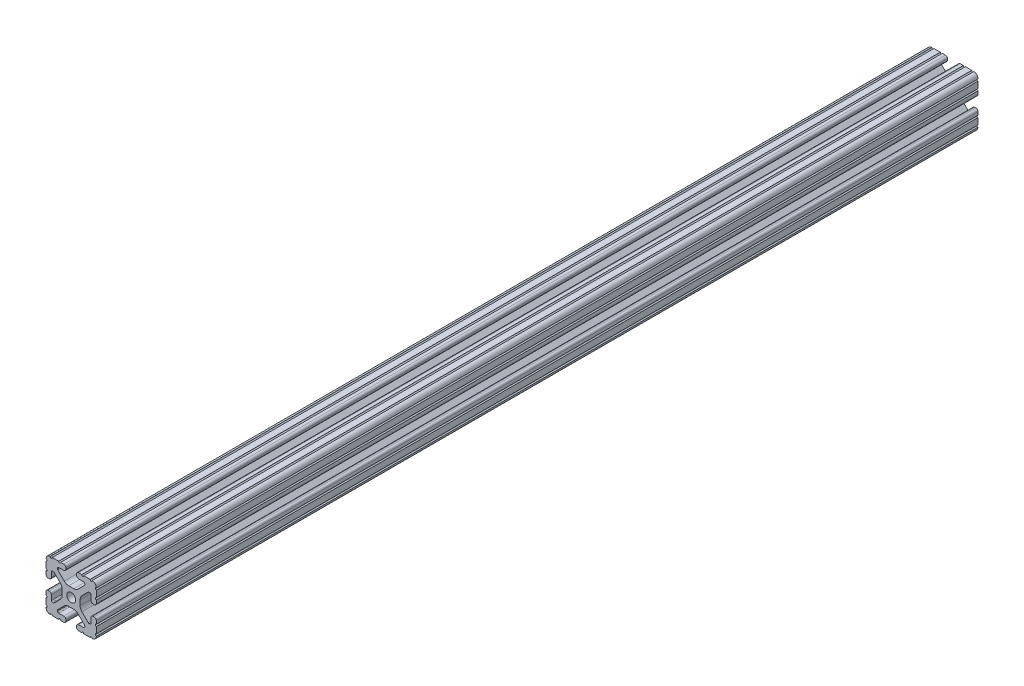
from build123d import *

# Parameters (mm, degrees)
SKETCH1_R               = 3.3274
BOSS_EXTRUDE1_DEPTH     = 609.6
SKETCH2_W               = 555.737416111
SKETCH2_H               = 51.354372661
CUT_EXTRUDE1_DEPTH      = 5.08
CUT_EXTRUDE1_DEPTH_BACK = 41.148


with BuildPart() as part:
    # Sketch1 → Boss-Extrude1 (new body, symmetric)
    with BuildSketch(Plane.XY):
        with BuildLine():
            Line((-10.287, 13.552357131), (-10.287, 14.0843))
            ThreePointArc((-10.287, 14.0843), (-10.022898185, 14.721898185), (-9.3853, 14.986))
            Line((-9.3853, 14.986), (-5.617617549, 14.986))
            ThreePointArc((-5.617617549, 14.986), (-4.519044045, 15.441044045), (-4.064, 16.539617549))
            Line((-4.064, 16.539617549), (-4.064, 17.496382451))
            ThreePointArc((-4.064, 17.496382451), (-4.519044045, 18.594955955), (-5.617617549, 19.05))
            Line((-5.617617549, 19.05), (-7.974178704, 19.05))
            ThreePointArc((-7.974178704, 19.05), (-8.736178704, 18.288), (-9.498178704, 19.05))
            Line((-9.498178704, 19.05), (-14.327719207, 19.05))
            ThreePointArc((-14.327719207, 19.05), (-15.087603123, 18.231251131), (-15.847487039, 19.05))
            ThreePointArc((-15.847487039, 19.05), (-18.120176289, 18.120192083), (-19.05, 15.847509295))
            ThreePointArc((-19.05, 15.847509295), (-18.231250992, 15.08762539), (-19.05, 14.327741484))
            Line((-19.05, 14.327741484), (-19.05, 9.496091471))
            ThreePointArc((-19.05, 9.496091471), (-18.231250992, 8.736207565), (-19.05, 7.97632366))
            Line((-19.05, 7.97632366), (-19.05, 5.617617549))
            ThreePointArc((-19.05, 5.617617549), (-18.594955955, 4.519044045), (-17.496382451, 4.064))
            Line((-17.496382451, 4.064), (-16.539617549, 4.064))
            ThreePointArc((-16.539617549, 4.064), (-15.441044045, 4.519044045), (-14.986, 5.617617549))
            Line((-14.986, 5.617617549), (-14.986, 9.385342516))
            ThreePointArc((-14.986, 9.385342516), (-14.721898185, 10.022940701), (-14.0843, 10.287042516))
            Line((-14.0843, 10.287042516), (-13.516042086, 10.287042516))
            ThreePointArc((-13.516042086, 10.287042516), (-13.170975923, 10.218404478), (-12.878443117, 10.022939917))
            Line((-12.878443117, 10.022939917), (-8.14758008, 5.292065243))
            ThreePointArc((-8.14758008, 5.292065243), (-7.117955879, 3.751120653), (-6.7564, 1.933453584))
            Line((-6.7564, 1.933453584), (-6.7564, -1.933453584))
            ThreePointArc((-6.7564, -1.933453584), (-7.117955879, -3.751120653), (-8.14758008, -5.292065243))
            Line((-8.14758008, -5.292065243), (-12.878443117, -10.022939917))
            ThreePointArc((-12.878443117, -10.022939917), (-13.170975923, -10.218404478), (-13.516042086, -10.287042516))
            Line((-13.516042086, -10.287042516), (-14.0843, -10.287042516))
            ThreePointArc((-14.0843, -10.287042516), (-14.721898185, -10.022940701), (-14.986, -9.385342516))
            Line((-14.986, -9.385342516), (-14.986, -5.617617549))
            ThreePointArc((-14.986, -5.617617549), (-15.441044045, -4.519044045), (-16.539617549, -4.064))
            Line((-16.539617549, -4.064), (-17.496382451, -4.064))
            ThreePointArc((-17.496382451, -4.064), (-18.594955955, -4.519044045), (-19.05, -5.617617549))
            Line((-19.05, -5.617617549), (-19.05, -7.976318491))
            ThreePointArc((-19.05, -7.976318491), (-18.231250992, -8.736202396), (-19.05, -9.496086302))
            Line((-19.05, -9.496086302), (-19.05, -14.32774291))
            ThreePointArc((-19.05, -14.32774291), (-18.231250992, -15.087626816), (-19.05, -15.847510721))
            ThreePointArc((-19.05, -15.847510721), (-18.120175716, -18.120192644), (-15.847486868, -19.05))
            ThreePointArc((-15.847486868, -19.05), (-15.087602952, -18.231251131), (-14.327719036, -19.05))
            Line((-14.327719036, -19.05), (-9.496062448, -19.05))
            ThreePointArc((-9.496062448, -19.05), (-8.736178532, -18.231251131), (-7.976294616, -19.05))
            Line((-7.976294616, -19.05), (-5.617617549, -19.05))
            ThreePointArc((-5.617617549, -19.05), (-4.519044045, -18.594955955), (-4.064, -17.496382451))
            Line((-4.064, -17.496382451), (-4.064, -16.539617549))
            ThreePointArc((-4.064, -16.539617549), (-4.519044045, -15.441044045), (-5.617617549, -14.986))
            Line((-5.617617549, -14.986), (-9.3853, -14.986))
            ThreePointArc((-9.3853, -14.986), (-10.022898185, -14.721898185), (-10.287, -14.0843))
            Line((-10.287, -14.0843), (-10.287, -13.552357131))
            ThreePointArc((-10.287, -13.552357131), (-10.218362387, -13.207291992), (-10.022898969, -12.91475973))
            Line((-10.022898969, -12.91475973), (-5.252158105, -8.144007132))
            ThreePointArc((-5.252158105, -8.144007132), (-3.715177372, -7.117027388), (-1.902183975, -6.7564))
            Line((-1.902183975, -6.7564), (1.902183975, -6.7564))
            ThreePointArc((1.902183975, -6.7564), (3.715177372, -7.117027388), (5.252158105, -8.144007132))
            Line((5.252158105, -8.144007132), (10.022898969, -12.91475973))
            ThreePointArc((10.022898969, -12.91475973), (10.218362387, -13.207291992), (10.287, -13.552357131))
            Line((10.287, -13.552357131), (10.287, -14.0843))
            ThreePointArc((10.287, -14.0843), (10.022898185, -14.721898185), (9.3853, -14.986))
            Line((9.3853, -14.986), (5.617617549, -14.986))
            ThreePointArc((5.617617549, -14.986), (4.519044045, -15.441044045), (4.064, -16.539617549))
            Line((4.064, -16.539617549), (4.064, -17.496382451))
            ThreePointArc((4.064, -17.496382451), (4.519044045, -18.594955955), (5.617617549, -19.05))
            Line((5.617617549, -19.05), (7.976294616, -19.05))
            ThreePointArc((7.976294616, -19.05), (8.736178532, -18.231251131), (9.496062448, -19.05))
            Line((9.496062448, -19.05), (14.327719036, -19.05))
            ThreePointArc((14.327719036, -19.05), (15.087602952, -18.231251131), (15.847486868, -19.05))
            ThreePointArc((15.847486868, -19.05), (18.120175716, -18.120192644), (19.05, -15.847510721))
            ThreePointArc((19.05, -15.847510721), (18.231250992, -15.087626816), (19.05, -14.32774291))
            Line((19.05, -14.32774291), (19.05, -9.496086302))
            ThreePointArc((19.05, -9.496086302), (18.231250992, -8.736202396), (19.05, -7.976318491))
            Line((19.05, -7.976318491), (19.05, -5.617617549))
            ThreePointArc((19.05, -5.617617549), (18.594955955, -4.519044045), (17.496382451, -4.064))
            Line((17.496382451, -4.064), (16.539617549, -4.064))
            ThreePointArc((16.539617549, -4.064), (15.441044045, -4.519044045), (14.986, -5.617617549))
            Line((14.986, -5.617617549), (14.986, -9.385342516))
            ThreePointArc((14.986, -9.385342516), (14.721898185, -10.022940701), (14.0843, -10.287042516))
            Line((14.0843, -10.287042516), (13.516042086, -10.287042516))
            ThreePointArc((13.516042086, -10.287042516), (13.170975923, -10.218404478), (12.878443117, -10.022939917))
            Line((12.878443117, -10.022939917), (8.14758008, -5.292065243))
            ThreePointArc((8.14758008, -5.292065243), (7.117955879, -3.751120653), (6.7564, -1.933453584))
            Line((6.7564, -1.933453584), (6.7564, 1.933453584))
            ThreePointArc((6.7564, 1.933453584), (7.117955879, 3.751120653), (8.14758008, 5.292065243))
            Line((8.14758008, 5.292065243), (12.878443117, 10.022939917))
            ThreePointArc((12.878443117, 10.022939917), (13.170975923, 10.218404478), (13.516042086, 10.287042516))
            Line((13.516042086, 10.287042516), (14.0843, 10.287042516))
            ThreePointArc((14.0843, 10.287042516), (14.721898185, 10.022940701), (14.986, 9.385342516))
            Line((14.986, 9.385342516), (14.986, 5.617617549))
            ThreePointArc((14.986, 5.617617549), (15.441044045, 4.519044045), (16.539617549, 4.064))
            Line((16.539617549, 4.064), (17.496382451, 4.064))
            ThreePointArc((17.496382451, 4.064), (18.594955955, 4.519044045), (19.05, 5.617617549))
            Line((19.05, 5.617617549), (19.05, 7.97632366))
            ThreePointArc((19.05, 7.97632366), (18.231250992, 8.736207565), (19.05, 9.496091471))
            Line((19.05, 9.496091471), (19.05, 14.327741484))
            ThreePointArc((19.05, 14.327741484), (18.231250992, 15.08762539), (19.05, 15.847509295))
            ThreePointArc((19.05, 15.847509295), (18.120176289, 18.120192083), (15.847487039, 19.05))
            ThreePointArc((15.847487039, 19.05), (15.087603123, 18.231251131), (14.327719207, 19.05))
            Line((14.327719207, 19.05), (9.498178704, 19.05))
            ThreePointArc((9.498178704, 19.05), (8.736178704, 18.288), (7.974178704, 19.05))
            Line((7.974178704, 19.05), (5.617617549, 19.05))
            ThreePointArc((5.617617549, 19.05), (4.519044045, 18.594955955), (4.064, 17.496382451))
            Line((4.064, 17.496382451), (4.064, 16.539617549))
            ThreePointArc((4.064, 16.539617549), (4.519044045, 15.441044045), (5.617617549, 14.986))
            Line((5.617617549, 14.986), (9.3853, 14.986))
            ThreePointArc((9.3853, 14.986), (10.022898185, 14.721898185), (10.287, 14.0843))
            Line((10.287, 14.0843), (10.287, 13.552357131))
            ThreePointArc((10.287, 13.552357131), (10.218362387, 13.207291992), (10.022898969, 12.91475973))
            Line((10.022898969, 12.91475973), (5.252158105, 8.144007132))
            ThreePointArc((5.252158105, 8.144007132), (3.715177372, 7.117027388), (1.902183975, 6.7564))
            Line((1.902183975, 6.7564), (-1.902183975, 6.7564))
            ThreePointArc((-1.902183975, 6.7564), (-3.715177372, 7.117027388), (-5.252158105, 8.144007132))
            Line((-5.252158105, 8.144007132), (-10.022898969, 12.91475973))
            ThreePointArc((-10.022898969, 12.91475973), (-10.218362387, 13.207291992), (-10.287, 13.552357131))
        make_face()
        Circle(SKETCH1_R, mode=Mode.SUBTRACT)
    extrude(amount=BOSS_EXTRUDE1_DEPTH, both=True)

    # Sketch2 → Cut-Extrude1 (cut, two sides)
    with BuildSketch(Plane(origin=(19.05, 0, 0), x_dir=(0, 0, -1), z_dir=(1, 0, 0))) as cut_extrude1_sk:
        with Locations((335.456045341, -0.9801838)):
            Rectangle(SKETCH2_W, SKETCH2_H)
    extrude(amount=CUT_EXTRUDE1_DEPTH, mode=Mode.SUBTRACT)
    extrude(cut_extrude1_sk.sketch, amount=-CUT_EXTRUDE1_DEPTH_BACK, mode=Mode.SUBTRACT)


solid = part.part
